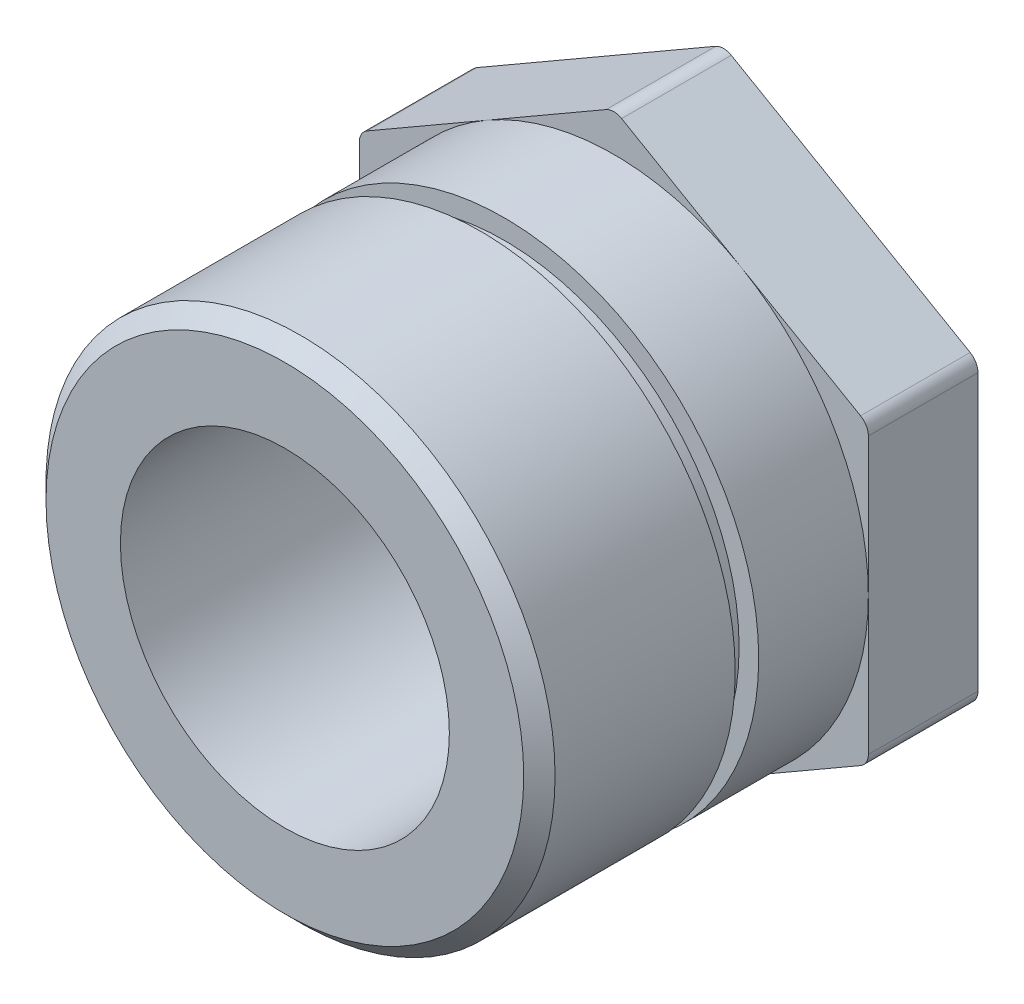
from build123d import *

# Parameters (mm, degrees)
SKETCH1_R           = 32.5
BOSS_EXTRUDE1_DEPTH = 42
CUT_EXTRUDE1_START  = -28
SKETCH2_R           = 32.5
SKETCH2_R_2         = 30
CUT_EXTRUDE1_DEPTH  = 3
BOSS_EXTRUDE3_DEPTH = 14
FILLET1_R           = 2
CHAMFER1_SIZE       = 2
SKETCH4_R           = 21
CUT_EXTRUDE4_DEPTH  = 57


with BuildPart() as part:
    # Sketch1 → Boss-Extrude1 (new body)
    with BuildSketch(Plane.XY):
        Circle(SKETCH1_R)
    extrude(amount=BOSS_EXTRUDE1_DEPTH)

    # Sketch2 → Cut-Extrude1 (cut)
    with BuildSketch(Plane.XY.offset(42).offset(CUT_EXTRUDE1_START)):
        Circle(SKETCH2_R)
        Circle(SKETCH2_R_2, mode=Mode.SUBTRACT)
    extrude(amount=CUT_EXTRUDE1_DEPTH, mode=Mode.SUBTRACT)

    # Sketch3 → Boss-Extrude3 (add)
    with BuildSketch(Plane(origin=(0, 0, 0), x_dir=(-1, 0, 0), z_dir=(0, 0, -1))):
        Polygon((32.5, -18.763883749), (32.5, 18.763883749), (0, 37.527767497), (-32.5, 18.763883749), (-32.5, -18.763883749), (0, -37.527767497), align=None)
    extrude(amount=BOSS_EXTRUDE3_DEPTH)

    # Fillet1
    fillet1_edges = [part.edges().sort_by_distance(p)[0] for p in [
        (0, -37.527767497, -7),
        (-32.5, -18.763883749, -7),
        (-32.5, 18.763883749, -7),
        (0, 37.527767497, -7),
        (32.5, 18.763883749, -7),
        (32.5, -18.763883749, -7),
    ]]
    fillet(fillet1_edges, radius=FILLET1_R)

    # Chamfer1
    chamfer1_edges = [part.edges().sort_by_distance(p)[0] for p in [
        (-32.5, 0, 42),
    ]]
    chamfer(chamfer1_edges, length=CHAMFER1_SIZE)

    # Sketch4 → Cut-Extrude4 (cut, through all)
    with BuildSketch(Plane.XY.offset(42)):
        Circle(SKETCH4_R)
    extrude(amount=-CUT_EXTRUDE4_DEPTH, mode=Mode.SUBTRACT)


solid = part.part
